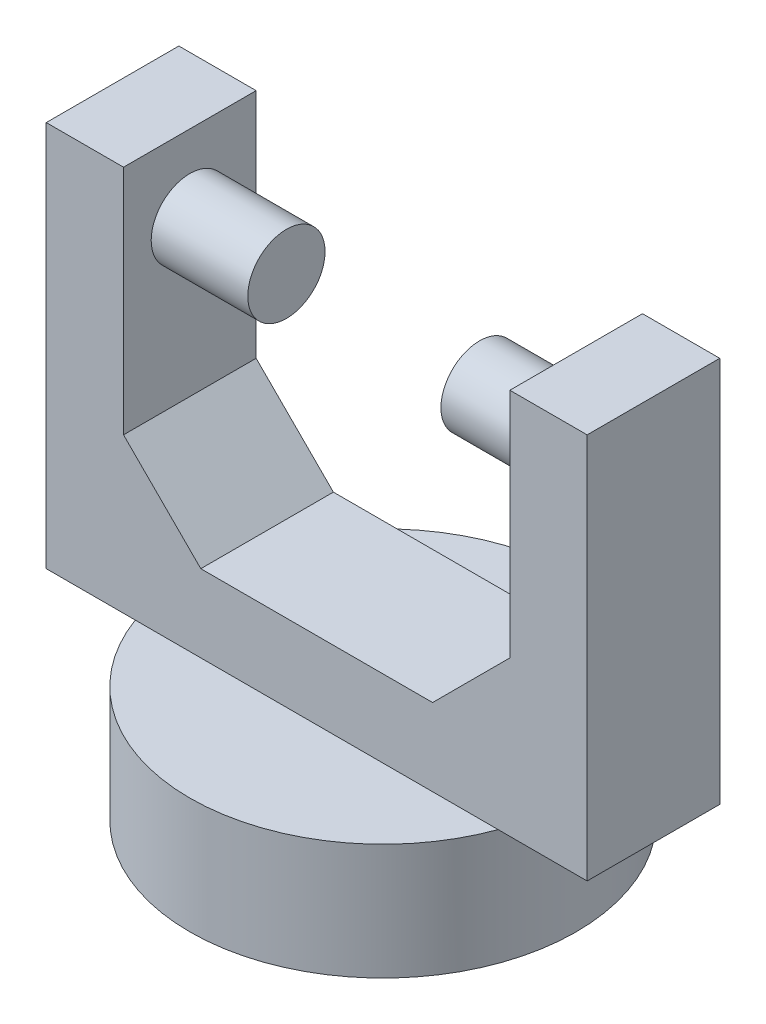
from build123d import *

# Parameters (mm, degrees)
SKETCH1_R           = 12.5
BOSS_EXTRUDE1_DEPTH = 7.5
SKETCH2_W           = 35
SKETCH2_H           = 8.580767914
BOSS_EXTRUDE2_DEPTH = 25
SKETCH3_W           = 25
SKETCH3_H           = 8.580767914
CUT_EXTRUDE1_DEPTH  = 20
SKETCH4_R           = 2.5
BOSS_EXTRUDE3_DEPTH = 6.25
SKETCH5_R           = 2.5
BOSS_EXTRUDE4_DEPTH = 6.25
CHAMFER1_SIZE       = 5
CHAMFER2_SIZE       = 5


with BuildPart() as part:
    # Sketch1 → Boss-Extrude1 (new body)
    with BuildSketch(Plane(origin=(0, 0, 0), x_dir=(1, 0, 0), z_dir=(0, 1, 0))):
        Circle(SKETCH1_R)
    extrude(amount=BOSS_EXTRUDE1_DEPTH)

    # Sketch2 → Boss-Extrude2 (add)
    with BuildSketch(Plane(origin=(0, 7.5, 0), x_dir=(1, 0, 0), z_dir=(0, 1, 0))):
        Rectangle(SKETCH2_W, SKETCH2_H)
    extrude(amount=BOSS_EXTRUDE2_DEPTH)

    # Sketch3 → Cut-Extrude1 (cut)
    with BuildSketch(Plane(origin=(0, 32.5, 0), x_dir=(1, 0, 0), z_dir=(0, 1, 0))):
        Rectangle(SKETCH3_W, SKETCH3_H)
    extrude(amount=-CUT_EXTRUDE1_DEPTH, mode=Mode.SUBTRACT)

    # Sketch4 → Boss-Extrude3 (add)
    with BuildSketch(Plane(origin=(-12.5, 0, 0), x_dir=(0, 0, -1), z_dir=(1, 0, 0))):
        with Locations((0, 27.5)):
            Circle(SKETCH4_R)
    extrude(amount=BOSS_EXTRUDE3_DEPTH)

    # Sketch5 → Boss-Extrude4 (add)
    with BuildSketch(Plane.ZY.offset(-12.5)):
        with Locations((0, 27.5)):
            Circle(SKETCH5_R)
    extrude(amount=BOSS_EXTRUDE4_DEPTH)

    # Chamfer1
    chamfer1_edges = [part.edges().sort_by_distance(p)[0] for p in [
        (-12.5, 12.5, 0),
    ]]
    chamfer(chamfer1_edges, length=CHAMFER1_SIZE)

    # Chamfer2
    chamfer2_edges = [part.edges().sort_by_distance(p)[0] for p in [
        (12.5, 12.5, 0),
    ]]
    chamfer(chamfer2_edges, length=CHAMFER2_SIZE)


solid = part.part
